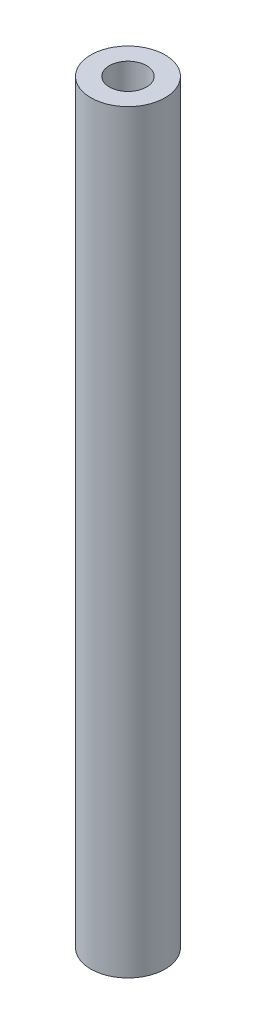
from build123d import *

# Parameters (mm, degrees)
SKETCH1_R                       = 5
BOSS_EXTRUDE1_DEPTH             = 101.6
M6X1_0_TAPPED_HOLE1_D           = 5
M6X1_0_TAPPED_HOLE1_CSINK_D     = 6.05
M6X1_0_TAPPED_HOLE1_CSINK_ANGLE = 90


with BuildPart() as part:
    # Sketch1 → Boss-Extrude1 (new body)
    with BuildSketch(Plane(origin=(0, 0, 0), x_dir=(1, 0, 0), z_dir=(0, 1, 0))):
        Circle(SKETCH1_R)
    extrude(amount=BOSS_EXTRUDE1_DEPTH)

    # M6x1.0 Tapped Hole1 (through all)
    with Locations(Plane(origin=(0, 0, 0), x_dir=(-1, 0, 0), z_dir=(0, -1, 0))):
        with Locations((0, 0)):
            CounterSinkHole(M6X1_0_TAPPED_HOLE1_D / 2, M6X1_0_TAPPED_HOLE1_CSINK_D / 2, counter_sink_angle=M6X1_0_TAPPED_HOLE1_CSINK_ANGLE)


solid = part.part
